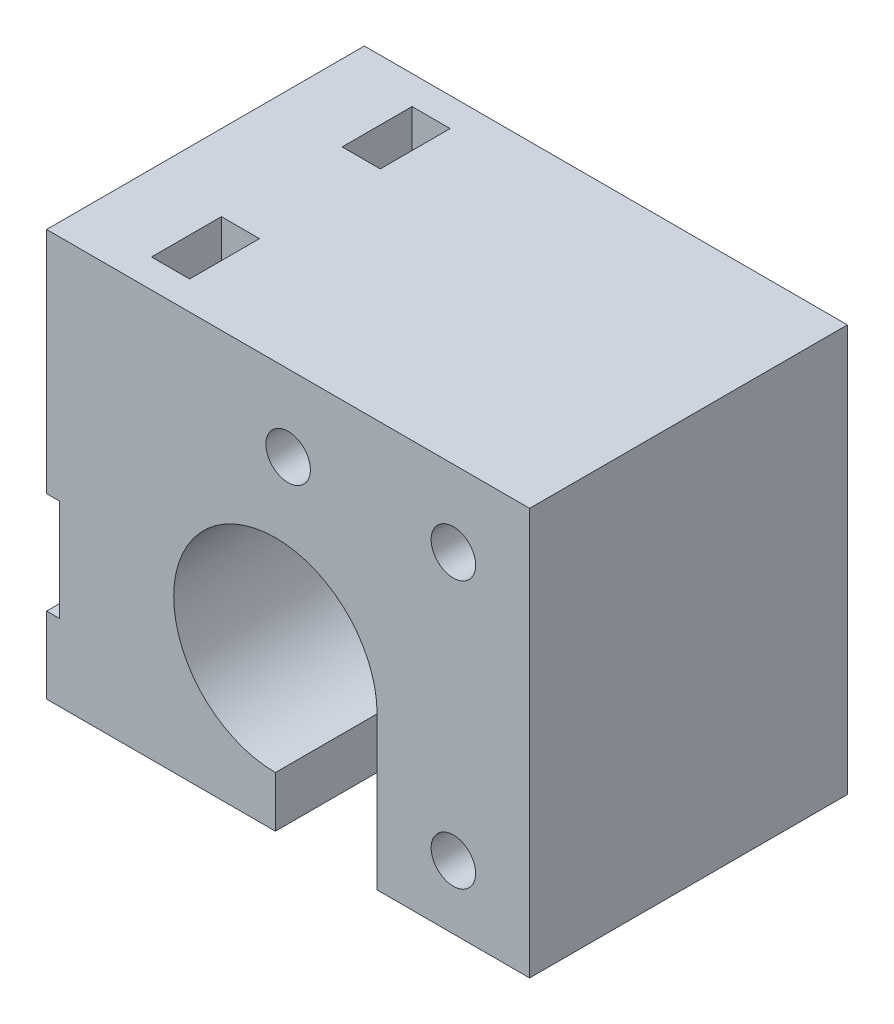
from build123d import *

# Parameters (mm, degrees)
SKETCH_2_R          = 1.75
EXTRUDE_1_DEPTH     = 25
SKETCH_3_W          = 1
SKETCH_3_H          = 8
CUT_EXTRUDE_1_DEPTH = 1
SKETCH_4_R          = 2
CUT_EXTRUDE_2_DEPTH = 9
SKETCH_5_W          = 3
SKETCH_5_H          = 5.5
CUT_EXTRUDE_3_DEPTH = 33


with BuildPart() as part:
    # Эскиз2 → Бобышка-Вытянуть1 (new body)
    with BuildSketch(Plane.XY):
        with BuildLine():
            Line((8, 0), (8, -12))
            Line((8, -12), (20, -12))
            Line((20, -12), (20, 20))
            Line((20, 20), (-18, 20))
            Line((-18, 20), (-18, -12))
            Line((-18, -12), (0, -12))
            Line((0, -12), (0, -8))
            ThreePointArc((0, -8), (-5.656854249, 5.656854249), (8, 0))
        make_face()
        with Locations((1, 14)):
            Circle(SKETCH_2_R, mode=Mode.SUBTRACT)
        with Locations((14, -7)):
            Circle(SKETCH_2_R, mode=Mode.SUBTRACT)
        with Locations((14, 14)):
            Circle(SKETCH_2_R, mode=Mode.SUBTRACT)
    extrude(amount=EXTRUDE_1_DEPTH)

    # Эскиз3 → Вырез-Вытянуть1 (cut)
    with BuildSketch(Plane.ZY.offset(18)):
        with Locations((0.5, -2)):
            Rectangle(SKETCH_3_W, SKETCH_3_H)
        with Locations((2.5, -2)):
            Rectangle(SKETCH_3_W, SKETCH_3_H)
        with Locations((4.5, -2)):
            Rectangle(SKETCH_3_W, SKETCH_3_H)
        with Locations((6.5, -2)):
            Rectangle(SKETCH_3_W, SKETCH_3_H)
        with Locations((8.5, -2)):
            Rectangle(SKETCH_3_W, SKETCH_3_H)
        with Locations((10.5, -2)):
            Rectangle(SKETCH_3_W, SKETCH_3_H)
        with Locations((12.5, -2)):
            Rectangle(SKETCH_3_W, SKETCH_3_H)
        with Locations((14.5, -2)):
            Rectangle(SKETCH_3_W, SKETCH_3_H)
        with Locations((16.5, -2)):
            Rectangle(SKETCH_3_W, SKETCH_3_H)
        with Locations((18.5, -2)):
            Rectangle(SKETCH_3_W, SKETCH_3_H)
        with Locations((20.5, -2)):
            Rectangle(SKETCH_3_W, SKETCH_3_H)
        with Locations((22.5, -2)):
            Rectangle(SKETCH_3_W, SKETCH_3_H)
        with Locations((24.5, -2)):
            Rectangle(SKETCH_3_W, SKETCH_3_H)
    extrude(amount=-CUT_EXTRUDE_1_DEPTH, mode=Mode.SUBTRACT)

    # Эскиз4 → Вырез-Вытянуть2 (cut)
    with BuildSketch(Plane.ZY.offset(18)):
        with Locations((5, 5)):
            Circle(SKETCH_4_R)
        with Locations((20, 5)):
            Circle(SKETCH_4_R)
        with Locations((20, -9)):
            Circle(SKETCH_4_R)
        with Locations((5, -9)):
            Circle(SKETCH_4_R)
    extrude(amount=-CUT_EXTRUDE_2_DEPTH, mode=Mode.SUBTRACT)

    # Эскиз5 → Вырез-Вытянуть3 (cut, through all)
    with BuildSketch(Plane.XZ.offset(12)):
        with Locations((-10.5, 5)):
            Rectangle(SKETCH_5_W, SKETCH_5_H)
        with Locations((-10.5, 20)):
            Rectangle(SKETCH_5_W, SKETCH_5_H)
    extrude(amount=-CUT_EXTRUDE_3_DEPTH, mode=Mode.SUBTRACT)


solid = part.part
